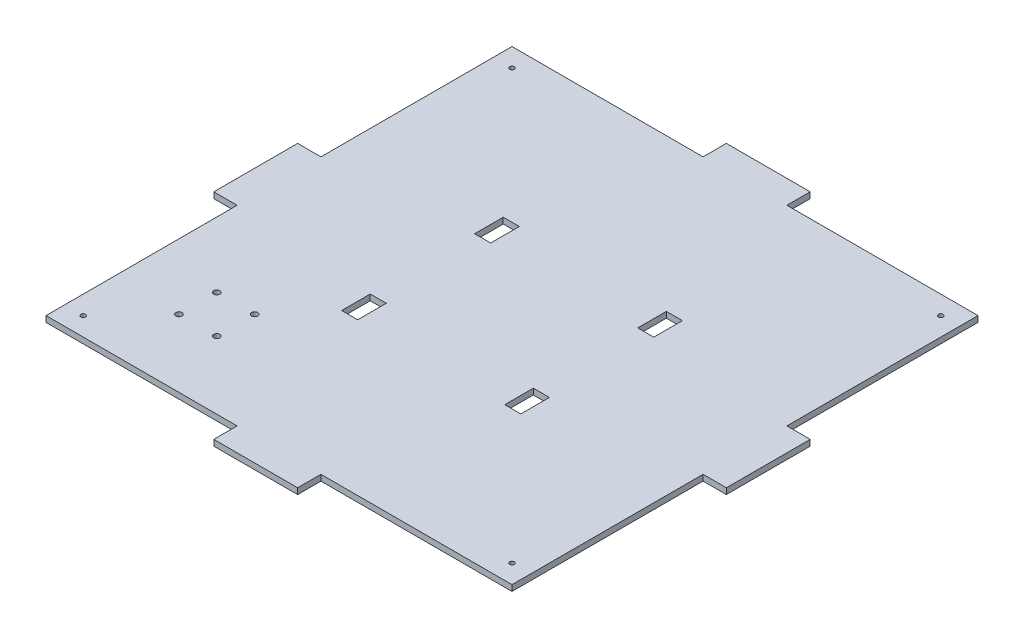
from build123d import *

# Parameters (mm, degrees)
SKETCH2_W           = 250
SKETCH2_H           = 250
BOSS_EXTRUDE1_DEPTH = 3.175
SKETCH3_W           = 8.6
SKETCH3_H           = 15.35
CUT_EXTRUDE1_DEPTH  = 10
SKETCH10_W          = 45
SKETCH10_H          = 3.175
BOSS_EXTRUDE2_DEPTH = 12.5
SKETCH11_W          = 45
SKETCH11_H          = 3.175
BOSS_EXTRUDE3_DEPTH = 12.5
SKETCH13_W          = 45
SKETCH13_H          = 3.175
BOSS_EXTRUDE4_DEPTH = 12.5
SKETCH14_W          = 45
SKETCH14_H          = 3.175
BOSS_EXTRUDE5_DEPTH = 12.5
M3_TAPPED_HOLE1_D   = 2.5
SKETCH21_R          = 1.25
CUT_EXTRUDE2_DEPTH  = 10
SKETCH22_R          = 1.651881978
SKETCH22_R_2        = 1.65156012
SKETCH22_R_3        = 1.651864629
SKETCH22_R_4        = 1.651
CUT_EXTRUDE3_DEPTH  = 4.175


with BuildPart() as part:
    # Sketch2 → Boss-Extrude1 (new body)
    with BuildSketch(Plane(origin=(0, 0, 0), x_dir=(1, 0, 0), z_dir=(0, 1, 0))):
        Rectangle(SKETCH2_W, SKETCH2_H)
    extrude(amount=BOSS_EXTRUDE1_DEPTH)

    # Sketch3 → Cut-Extrude1 (cut)
    with BuildSketch(Plane(origin=(0, 3.175, 0), x_dir=(1, 0, 0), z_dir=(0, 1, 0))):
        with Locations((-43.75, 35.675)):
            Rectangle(SKETCH3_W, SKETCH3_H)
        with Locations((-43.75, -35.675)):
            Rectangle(SKETCH3_W, SKETCH3_H)
        with Locations((43.75, -35.675)):
            Rectangle(SKETCH3_W, SKETCH3_H)
        with Locations((43.75, 35.675)):
            Rectangle(SKETCH3_W, SKETCH3_H)
    extrude(amount=-CUT_EXTRUDE1_DEPTH, mode=Mode.SUBTRACT)

    # Sketch10 → Boss-Extrude2 (add)
    with BuildSketch(Plane(origin=(0, 0, -125), x_dir=(-1, 0, 0), z_dir=(0, 0, -1))):
        with Locations((0, 1.5875)):
            Rectangle(SKETCH10_W, SKETCH10_H)
    extrude(amount=BOSS_EXTRUDE2_DEPTH)

    # Sketch11 → Boss-Extrude3 (add)
    with BuildSketch(Plane.ZY.offset(125)):
        with Locations((0, 1.5875)):
            Rectangle(SKETCH11_W, SKETCH11_H)
    extrude(amount=BOSS_EXTRUDE3_DEPTH)

    # Sketch13 → Boss-Extrude4 (add)
    with BuildSketch(Plane.XY.offset(125)):
        with Locations((0, 1.5875)):
            Rectangle(SKETCH13_W, SKETCH13_H)
    extrude(amount=BOSS_EXTRUDE4_DEPTH)

    # Sketch14 → Boss-Extrude5 (add)
    with BuildSketch(Plane(origin=(125, 0, 0), x_dir=(0, 0, -1), z_dir=(1, 0, 0))):
        with Locations((0, 1.5875)):
            Rectangle(SKETCH14_W, SKETCH14_H)
    extrude(amount=BOSS_EXTRUDE5_DEPTH)

    # M3 Tapped Hole1 (through all)
    with Locations(Plane(origin=(-115, 3.175, -115), x_dir=(0, 0, 1), z_dir=(0, 1, 0))):
        with Locations((0, 0)):
            Hole(M3_TAPPED_HOLE1_D / 2)

    # Sketch21 → Cut-Extrude2 (cut)
    with BuildSketch(Plane(origin=(0, 3.175, 0), x_dir=(1, 0, 0), z_dir=(0, 1, 0))):
        with Locations((115, 115)):
            Circle(SKETCH21_R)
        with Locations((115, -115)):
            Circle(SKETCH21_R)
        with Locations((-115, -115)):
            Circle(SKETCH21_R)
    extrude(amount=-CUT_EXTRUDE2_DEPTH, mode=Mode.SUBTRACT)

    # Sketch22 → Cut-Extrude3 (cut, through all)
    with BuildSketch(Plane(origin=(0, 3.175, 0), x_dir=(1, 0, 0), z_dir=(0, 1, 0))):
        with Locations((-89.96501808, -68.404219496)):
            Circle(SKETCH22_R)
        with Locations((-69.644539433, -68.404527337)):
            Circle(SKETCH22_R_2)
        with Locations((-69.644998895, -88.724239252)):
            Circle(SKETCH22_R_3)
        with Locations((-89.965017771, -88.724219998)):
            Circle(SKETCH22_R_4)
    extrude(amount=-CUT_EXTRUDE3_DEPTH, mode=Mode.SUBTRACT)


solid = part.part
